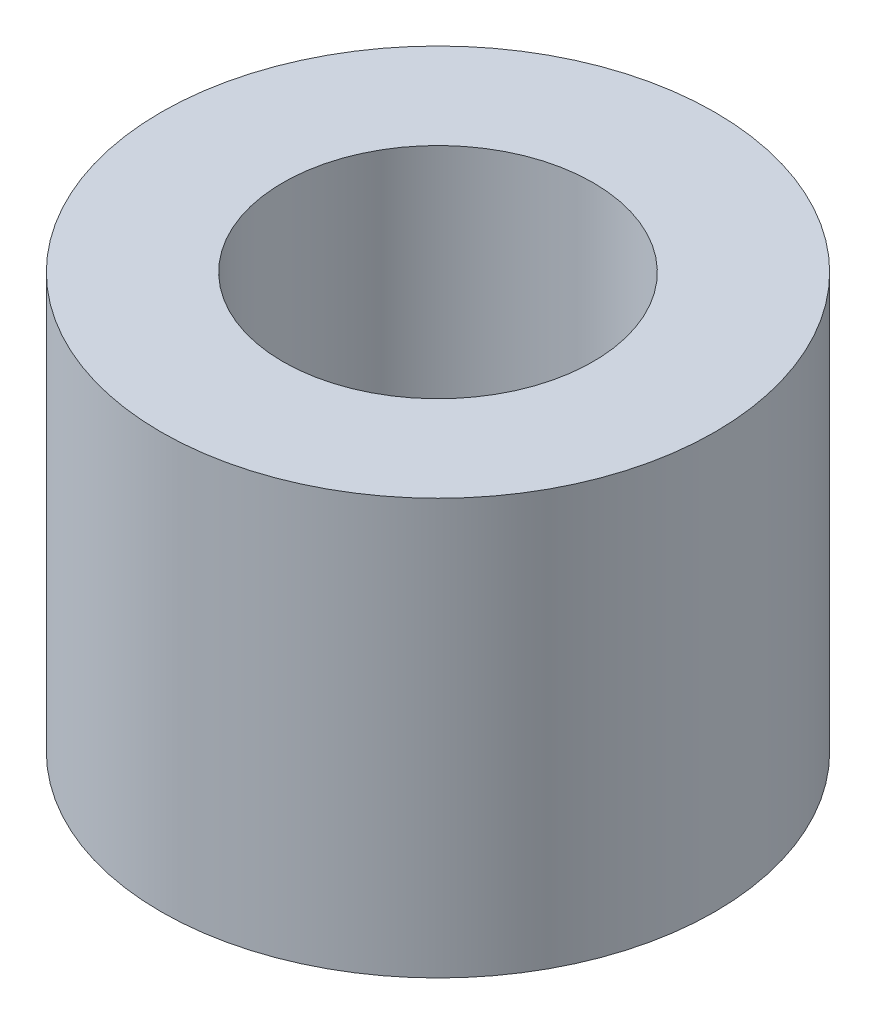
from build123d import *

# Parameters (mm, degrees)
SKETCH1_R                 = 3.175
BOSS_EXTRUDE1_DEPTH       = 4.7625
F_6_CLEARANCE_HOLE1_D     = 3.556
F_6_CLEARANCE_HOLE1_DEPTH = 7.62
F_6_CLEARANCE_HOLE1_TIP   = 1.068330181


with BuildPart() as part:
    # Sketch1 → Boss-Extrude1 (new body)
    with BuildSketch(Plane(origin=(0, 0, 0), x_dir=(1, 0, 0), z_dir=(0, 1, 0))):
        Circle(SKETCH1_R)
    extrude(amount=BOSS_EXTRUDE1_DEPTH)

    # #6 Clearance Hole1
    with Locations(Plane(origin=(0, 4.7625, 0), x_dir=(-1, 0, 0), z_dir=(0, 1, 0))):
        with Locations((0, 0)):
            Hole(F_6_CLEARANCE_HOLE1_D / 2, depth=F_6_CLEARANCE_HOLE1_DEPTH)
            with Locations((0, 0, -(F_6_CLEARANCE_HOLE1_DEPTH + F_6_CLEARANCE_HOLE1_TIP / 2))):  # 118° drill point
                Cone(0, F_6_CLEARANCE_HOLE1_D / 2, F_6_CLEARANCE_HOLE1_TIP, mode=Mode.SUBTRACT)


solid = part.part
